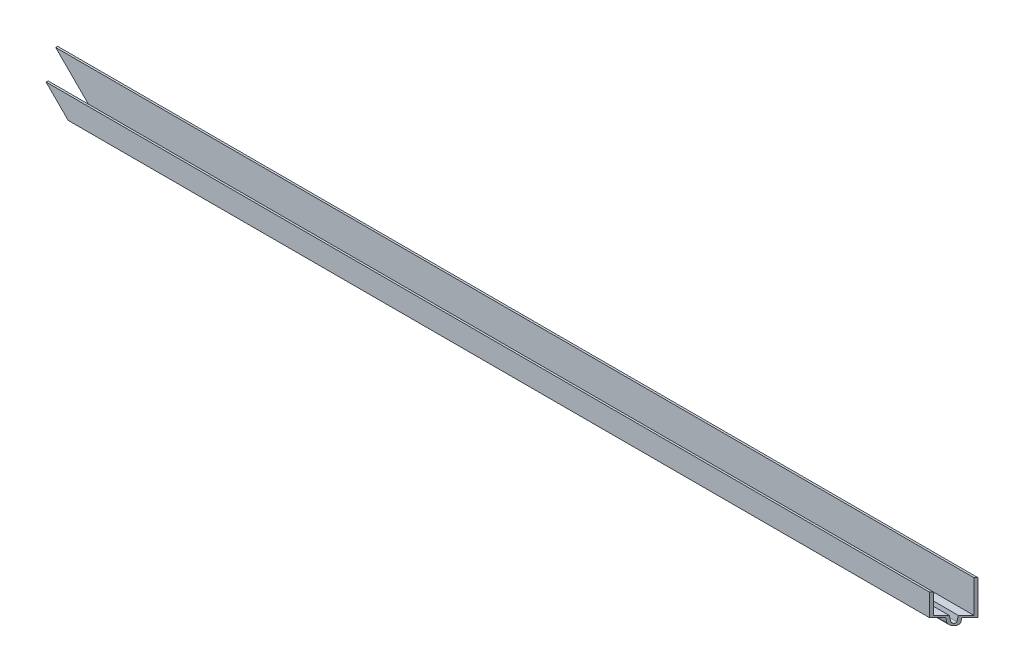
from build123d import *

# Parameters (mm, degrees)
BOSS_EXTRUDE1_DEPTH         = 289.71875
CUT_TOP_RIGHT_FRONT_DEPTH   = 27.162
CUT_FRONT_LEFT_BOTTOM_DEPTH = 16.24


with BuildPart() as part:
    # Sketch1 → Boss-Extrude1 (new body, symmetric)
    with BuildSketch(Plane(origin=(0, 0, 0), x_dir=(0, 0, -1), z_dir=(1, 0, 0))):
        with BuildLine():
            Line((7.62, 0), (7.62, -21.844))
            Line((7.62, -21.844), (2.54, -21.844))
            Line((2.54, -21.844), (2.202186415, -24.247668555))
            ThreePointArc((2.202186415, -24.247668555), (0, -26.162), (-2.202186415, -24.247668555))
            Line((-2.202186415, -24.247668555), (-2.54, -21.844))
            Line((-2.54, -21.844), (-7.62, -21.844))
            Line((-7.62, -21.844), (-7.62, -7.874))
            Line((-7.62, -7.874), (-6.35, -7.874))
            Line((-6.35, -7.874), (-6.35, -20.574))
            Line((-6.35, -20.574), (-1.436005843, -20.574))
            Line((-1.436005843, -20.574), (-0.944545968, -24.070918717))
            ThreePointArc((-0.944545968, -24.070918717), (0, -24.892), (0.944545968, -24.070918717))
            Line((0.944545968, -24.070918717), (1.436005843, -20.574))
            Line((1.436005843, -20.574), (6.35, -20.574))
            Line((6.35, -20.574), (6.35, 0))
            Line((6.35, 0), (7.62, 0))
        make_face()
    extrude(amount=BOSS_EXTRUDE1_DEPTH, both=True)

    # Sketch2 → Cut-Top-Right-Front (cut, through all)
    with BuildSketch(Plane(origin=(0, 0, 0), x_dir=(1, 0, 0), z_dir=(0, 1, 0))):
        Polygon((289.71875, 7.62), (274.47875, -7.62), (289.71875, -7.62), align=None)
    extrude(amount=-CUT_TOP_RIGHT_FRONT_DEPTH, mode=Mode.SUBTRACT)

    # Sketch12 → Cut-Front-Left-Bottom (cut, through all)
    with BuildSketch(Plane.XY.offset(7.62)):
        Polygon((-289.71875, 0), (-263.55675, -26.162), (-289.71875, -26.162), align=None)
    extrude(amount=-CUT_FRONT_LEFT_BOTTOM_DEPTH, mode=Mode.SUBTRACT)


solid = part.part
